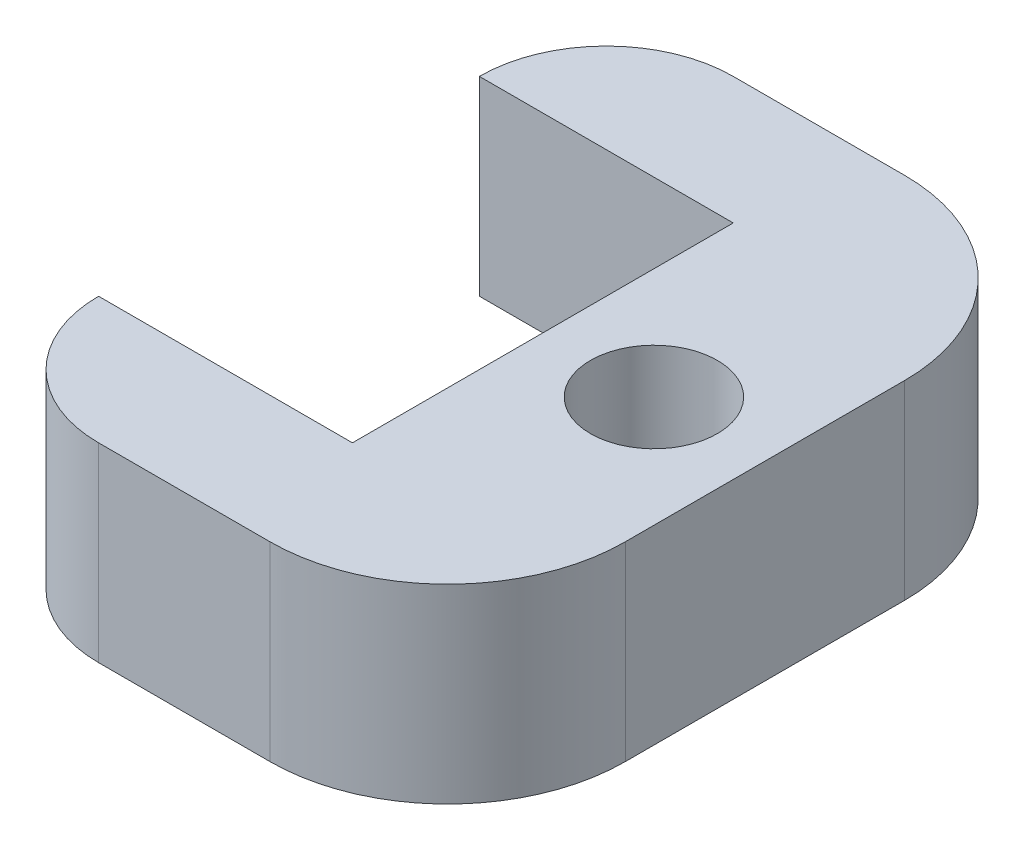
from build123d import *

# Parameters (mm, degrees)
SKETCH2_R           = 12.7
BOSS_EXTRUDE1_DEPTH = 38.1


with BuildPart() as part:
    # Sketch2 → Boss-Extrude1 (new body)
    with BuildSketch(Plane(origin=(0, 0, 0), x_dir=(1, 0, 0), z_dir=(0, 1, 0))):
        with BuildLine():
            Line((0, -38.1), (0, 38.1))
            Line((0, 38.1), (-50.8, 38.1))
            ThreePointArc((-50.8, 38.1), (-43.360512242, 56.060512242), (-25.4, 63.5))
            Line((-25.4, 63.5), (8.89, 63.5))
            ThreePointArc((8.89, 63.5), (34.034717139, 53.084717139), (44.45, 27.94))
            Line((44.45, 27.94), (44.45, -27.94))
            ThreePointArc((44.45, -27.94), (34.034717139, -53.084717139), (8.89, -63.5))
            Line((8.89, -63.5), (-25.4, -63.5))
            ThreePointArc((-25.4, -63.5), (-43.360512242, -56.060512242), (-50.8, -38.1))
            Line((-50.8, -38.1), (0, -38.1))
        make_face()
        with Locations((22.225, 0)):
            Circle(SKETCH2_R, mode=Mode.SUBTRACT)
    extrude(amount=BOSS_EXTRUDE1_DEPTH)


solid = part.part
